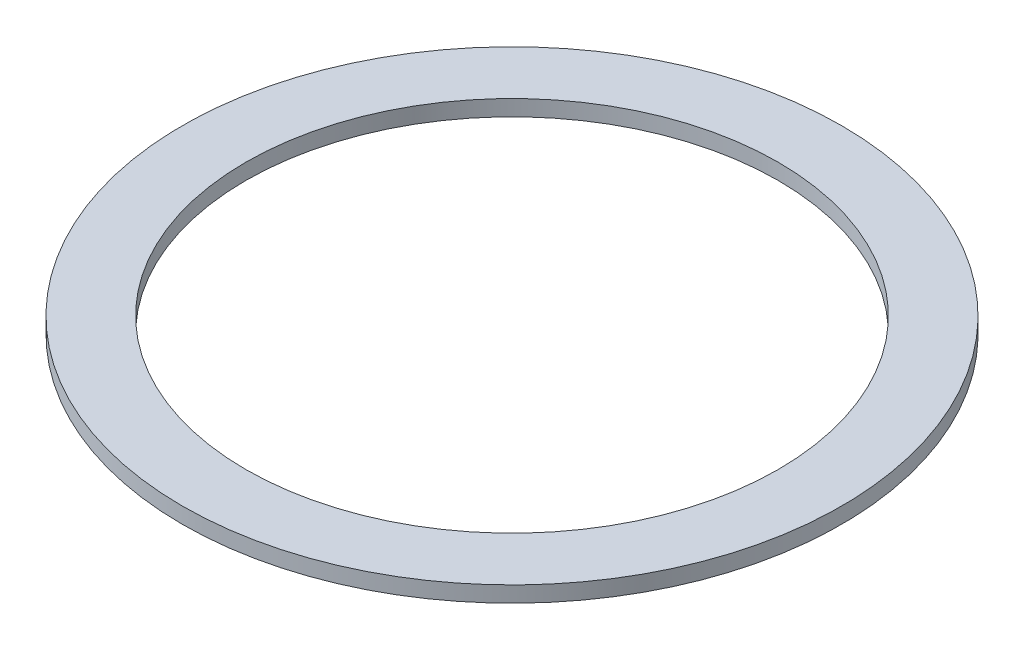
from build123d import *

# Parameters (mm, degrees)
SKETCH1_R           = 33.02
SKETCH1_R_2         = 26.67
BOSS_EXTRUDE1_DEPTH = 1.5875


with BuildPart() as part:
    # Sketch1 → Boss-Extrude1 (new body)
    with BuildSketch(Plane(origin=(0, 0, 0), x_dir=(1, 0, 0), z_dir=(0, 1, 0))):
        Circle(SKETCH1_R)
        Circle(SKETCH1_R_2, mode=Mode.SUBTRACT)
    extrude(amount=BOSS_EXTRUDE1_DEPTH)


solid = part.part
